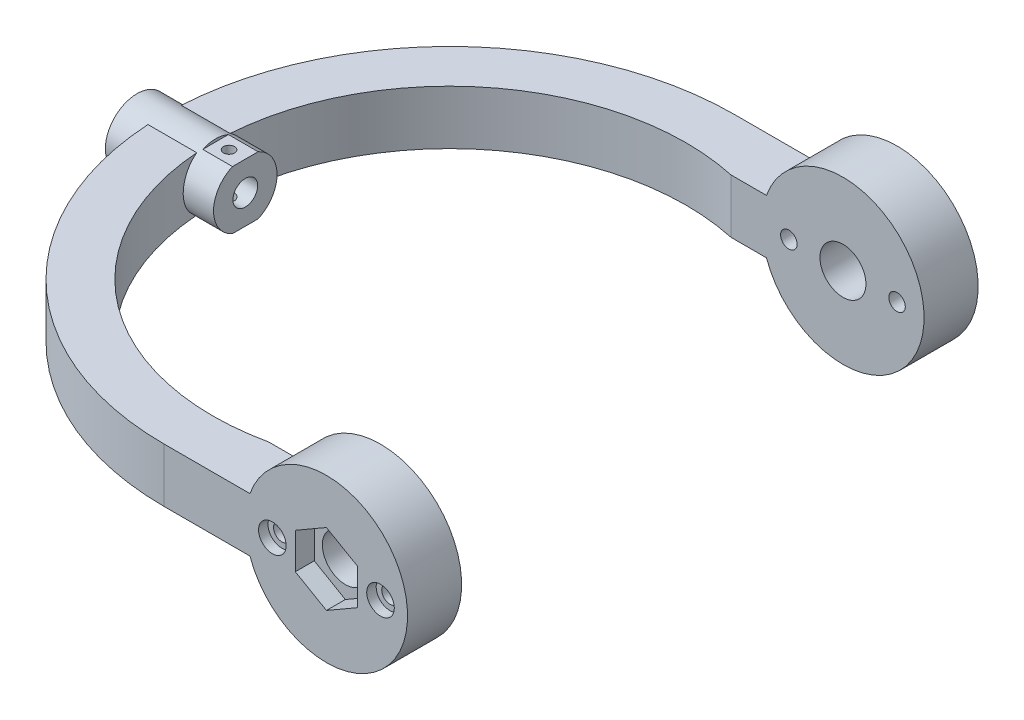
from build123d import *
from build123d.topology import SkipClean

# Parameters (mm, degrees)
BOSS_EXTRUDE1_DEPTH      = 10
BOSS_EXTRUDE1_DEPTH_BACK = 10
SKETCH2_R                = 30
BOSS_EXTRUDE2_DEPTH      = 20
CUT_EXTRUDE1_REACH       = 239.805
SKETCH3_R                = 8.5
SKETCH3_R_2              = 3.05
CUT_EXTRUDE3_DEPTH       = 155.468443379
SKETCH7_R                = 8.5
CUT_EXTRUDE4_DEPTH       = 7
BOSS_EXTRUDE3_DEPTH      = 10
BOSS_EXTRUDE3_DEPTH_BACK = 20
SKETCH8_R                = 11.75
SKETCH9_R                = 8.75
CUT_EXTRUDE5_DEPTH       = 8
SKETCH10_R               = 4.57
CUT_EXTRUDE6_DEPTH       = 226.912593764
SKETCH11_R               = 11.75
SKETCH11_R_2             = 4.57
BOSS_EXTRUDE4_DEPTH      = 10
CUT_EXTRUDE7_DEPTH       = 160.281198025
CUT_EXTRUDE7_DEPTH_BACK  = 160.281198025
SKETCH12_R               = 2.05
SKETCH13_R               = 5.1
SKETCH13_R_2             = 3.05
CUT_EXTRUDE8_DEPTH       = 3.5
SKETCH14_W               = 11
SKETCH14_H               = 23.5
CUT_EXTRUDE9_DEPTH       = 1


with BuildPart() as part:
    # Sketch1 → Boss-Extrude1 (new, two sides: drawn at the far end of the back side and taken through both)
    with BuildSketch(Plane(origin=(0, 0, 0), x_dir=(1, 0, 0), z_dir=(0, 1, 0)).offset(-BOSS_EXTRUDE1_DEPTH_BACK)):
        with BuildLine():
            ThreePointArc((0, -85.5), (-85.5, 0), (0, 85.5))
            Line((0, 85.5), (80, 85.5))
            Line((80, 85.5), (80, 105.5))
            Line((80, 105.5), (0, 105.5))
            ThreePointArc((0, 105.5), (-105.5, 0), (0, -105.5))
            Line((0, -105.5), (80, -105.5))
            Line((80, -105.5), (80, -85.5))
            Line((80, -85.5), (0, -85.5))
        make_face()
    extrude(amount=BOSS_EXTRUDE1_DEPTH + BOSS_EXTRUDE1_DEPTH_BACK)

    # Sketch2 → Boss-Extrude2 (add)
    with BuildSketch(Plane.XY.offset(105.5)):
        with Locations((60, 0)):
            Circle(SKETCH2_R)
    boss_extrude2 = extrude(amount=-BOSS_EXTRUDE2_DEPTH)

    # Sketch3 → Cut-Extrude1 (cut, up to next)
    with BuildSketch(Plane.XY.offset(105.5), mode=Mode.PRIVATE) as cut_extrude1_sk1:
        with Locations((60, 0)):
            Circle(SKETCH3_R)
    cut_extrude1_tool1 = extrude(cut_extrude1_sk1.sketch, amount=-CUT_EXTRUDE1_REACH, mode=Mode.PRIVATE) & part.part
    # Sketch3 → Cut-Extrude1 (cut, up to next)
    with BuildSketch(Plane.XY.offset(105.5), mode=Mode.PRIVATE) as cut_extrude1_sk2:
        with Locations((80, 0)):
            Circle(SKETCH3_R_2)
    cut_extrude1_tool2 = extrude(cut_extrude1_sk2.sketch, amount=-CUT_EXTRUDE1_REACH, mode=Mode.PRIVATE) & part.part
    # Sketch3 → Cut-Extrude1 (cut, up to next)
    with BuildSketch(Plane.XY.offset(105.5), mode=Mode.PRIVATE) as cut_extrude1_sk3:
        with Locations((40, 0)):
            Circle(SKETCH3_R_2)
    cut_extrude1_tool3 = extrude(cut_extrude1_sk3.sketch, amount=-CUT_EXTRUDE1_REACH, mode=Mode.PRIVATE) & part.part
    cut_extrude1_1 = cut_extrude1_tool1.solids().sort_by_distance((60, 0, 105.5))[0]
    add(cut_extrude1_1, mode=Mode.SUBTRACT)
    cut_extrude1_2 = cut_extrude1_tool2.solids().sort_by_distance((80, 0, 105.5))[0]
    add(cut_extrude1_2, mode=Mode.SUBTRACT)
    cut_extrude1_3 = cut_extrude1_tool3.solids().sort_by_distance((40, 0, 105.5))[0]
    add(cut_extrude1_3, mode=Mode.SUBTRACT)
    cut_extrude1 = cut_extrude1_1 + cut_extrude1_2 + cut_extrude1_3  # Cut-Extrude1 as one shape, for the pattern or mirror that repeats it

    # Mirror2: Boss-Extrude2, Cut-Extrude1 across plane
    add(boss_extrude2.mirror(Plane.XY))
    add(cut_extrude1.mirror(Plane.XY), mode=Mode.SUBTRACT)

    # Sketch6 → Cut-Extrude3 (cut, through all)
    with BuildSketch(Plane(origin=(0, 10, 0), x_dir=(1, 0, 0), z_dir=(0, 1, 0))):
        with BuildLine():
            Line((31.715728753, 81.549755056), (31.715728753, -81.549755056))
            ThreePointArc((31.715728753, -81.549755056), (-87.5, 0), (31.715728753, 81.549755056))
        make_face()
    extrude(amount=-CUT_EXTRUDE3_DEPTH, mode=Mode.SUBTRACT)

    # Sketch7 → Cut-Extrude4 (cut)
    with BuildSketch(Plane.XY.offset(105.5)):
        Polygon((60, 13.279056191), (48.5, 6.639528096), (48.5, -6.639528096), (60, -13.279056191), (71.5, -6.639528096), (71.5, 6.639528096), align=None)
        with Locations((60, 0)):
            Circle(SKETCH7_R, mode=Mode.SUBTRACT)
    cut_extrude4 = extrude(amount=-CUT_EXTRUDE4_DEPTH, mode=Mode.SUBTRACT)

    # Mirror3: Cut-Extrude4 across plane
    add(cut_extrude4.mirror(Plane.XY), mode=Mode.SUBTRACT)

    # Sketch8 → Boss-Extrude3 (add, two sides: drawn at the far end of the back side and taken through both)
    with BuildSketch(Plane.ZY.offset(105.5).offset(-BOSS_EXTRUDE3_DEPTH_BACK)):
        Circle(SKETCH8_R)
    extrude(amount=BOSS_EXTRUDE3_DEPTH + BOSS_EXTRUDE3_DEPTH_BACK)

    # Sketch9 → Cut-Extrude5 (cut)
    with BuildSketch(Plane.ZY.offset(115.5)):
        Circle(SKETCH9_R)
    extrude(amount=-CUT_EXTRUDE5_DEPTH, mode=Mode.SUBTRACT)

    # Sketch10 → Cut-Extrude6 (cut, through all)
    with BuildSketch(Plane.ZY.offset(107.5)):
        Circle(SKETCH10_R)
    extrude(amount=-CUT_EXTRUDE6_DEPTH, mode=Mode.SUBTRACT)

    # Sketch11 → Boss-Extrude4 (add)
    with BuildSketch(Plane(origin=(-85.5, 0, 0), x_dir=(0, 0, -1), z_dir=(1, 0, 0))):
        Circle(SKETCH11_R)
        Circle(SKETCH11_R_2, mode=Mode.SUBTRACT)
    extrude(amount=BOSS_EXTRUDE4_DEPTH)

    # Sketch12 → Cut-Extrude7 (cut, two sides: drawn at the far end of the back side and taken through both)
    with BuildSketch(Plane(origin=(0, 0, 0), x_dir=(1, 0, 0), z_dir=(0, 1, 0)).offset(-CUT_EXTRUDE7_DEPTH_BACK)):
        with Locations((-81.5, 0)):
            Circle(SKETCH12_R)
    extrude(amount=CUT_EXTRUDE7_DEPTH + CUT_EXTRUDE7_DEPTH_BACK, mode=Mode.SUBTRACT)

    # Sketch13 → Cut-Extrude8 (cut)
    # profile 1 of 2: a face of its own
    with BuildSketch(Plane.XY.offset(105.5)):
        with Locations((40, 0)):
            Circle(SKETCH13_R)
        with Locations((40, 0)):
            Circle(SKETCH13_R_2, mode=Mode.SUBTRACT)
    # profile 2 of 2: a face of its own
    with BuildSketch(Plane.XY.offset(105.5)):
        with Locations((80, 0)):
            Circle(SKETCH13_R)
        with Locations((80, 0)):
            Circle(SKETCH13_R_2, mode=Mode.SUBTRACT)
    cut_extrude8 = extrude(amount=-CUT_EXTRUDE8_DEPTH, mode=Mode.SUBTRACT)

    # Mirror4: Cut-Extrude8 across plane
    add(cut_extrude8.mirror(Plane.XY), mode=Mode.SUBTRACT)

    # Sketch14 → Cut-Extrude9 (cut)
    with SkipClean():  # the faces are left unmerged after this step: merging them gives an invalid solid
        with BuildSketch(Plane(origin=(0, 11.75, 0), x_dir=(1, 0, 0), z_dir=(0, 1, 0))):
            with Locations((-81, 0)):
                Rectangle(SKETCH14_W, SKETCH14_H)
        cut_extrude9 = extrude(amount=-CUT_EXTRUDE9_DEPTH, mode=Mode.SUBTRACT)

    # Mirror5: Cut-Extrude9 across plane
    with SkipClean():  # the faces are left unmerged after this step: merging them gives an invalid solid
        add(cut_extrude9.mirror(Plane.ZX), mode=Mode.SUBTRACT)


solid = part.part
